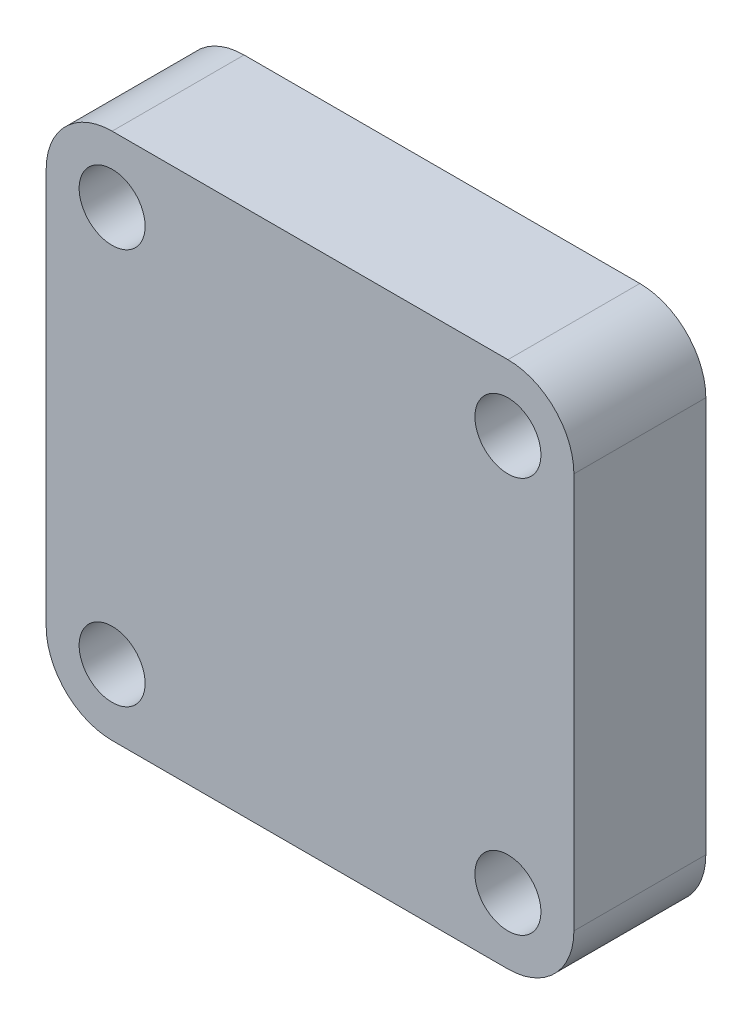
from build123d import *

# Parameters (mm, degrees)
SKETCH1_W               = 40
SKETCH1_H               = 40
BOSS_EXTRUDE1_DEPTH     = 10
SKETCH2_R               = 2.5
CUT_EXTRUDE1_DEPTH      = 11
MIRROR2_COPY_1_SKETCH_R = 2.5
MIRROR2_COPY_1_DEPTH    = 11
FILLET2_R               = 5


with BuildPart() as part:
    # Sketch1 → Boss-Extrude1 (new body)
    with BuildSketch(Plane.XY):
        with Locations((20, 20)):
            Rectangle(SKETCH1_W, SKETCH1_H)
    extrude(amount=BOSS_EXTRUDE1_DEPTH)

    # Sketch2 → Cut-Extrude1 (cut, through all)
    with BuildSketch(Plane.XY.offset(10)):
        with Locations((5, 35)):
            Circle(SKETCH2_R)
    cut_extrude1 = extrude(amount=-CUT_EXTRUDE1_DEPTH, mode=Mode.SUBTRACT)

    # Mirror1: Cut-Extrude1 across plane
    add(cut_extrude1.mirror(Plane.ZX.offset(20)), mode=Mode.SUBTRACT)

    # Mirror2: Cut-Extrude1 across plane
    add(cut_extrude1.mirror(Plane(origin=(20, 0, 0), x_dir=(0, 0, 1), z_dir=(1, 0, 0))), mode=Mode.SUBTRACT)

    # Mirror2 copy 1 sketch → Mirror2 copy 1 (cut, through all)
    with BuildSketch(Plane(origin=(40, 40, 10), x_dir=(-1, 0, 0), z_dir=(0, 0, 1))):
        with Locations((5, 35)):
            Circle(MIRROR2_COPY_1_SKETCH_R)
    extrude(amount=-MIRROR2_COPY_1_DEPTH, mode=Mode.SUBTRACT)

    # Fillet2
    fillet2_edges = [part.edges().sort_by_distance(p)[0] for p in [
        (0, 40, 5),
        (40, 40, 5),
        (40, 0, 5),
        (0, 0, 5),
    ]]
    fillet(fillet2_edges, radius=FILLET2_R)


solid = part.part
